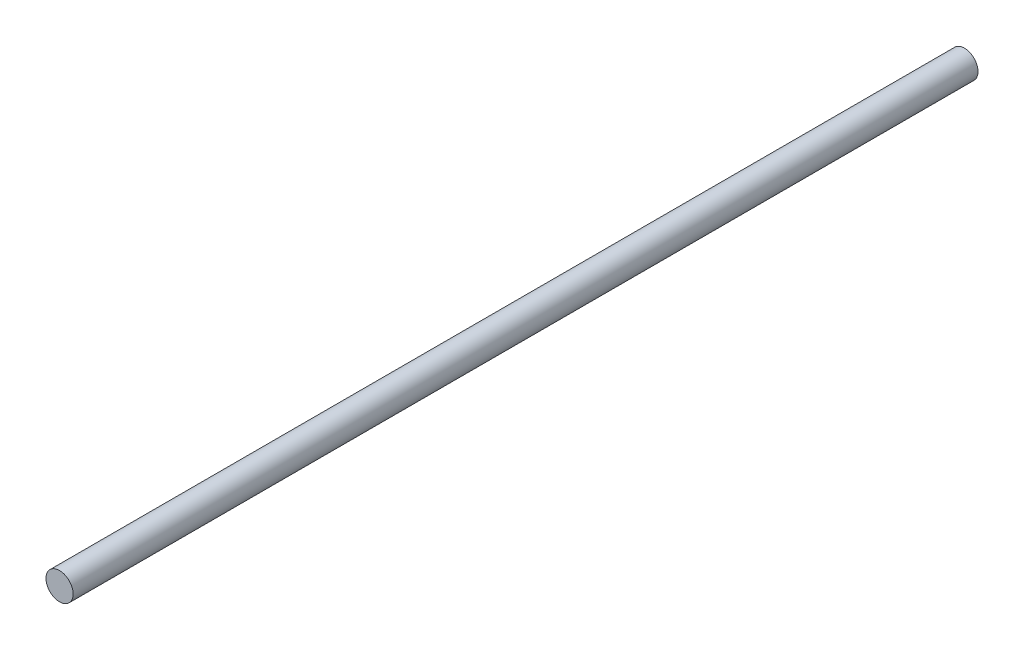
from build123d import *

# Parameters (mm, degrees)
SKETCH1_R           = 3
BOSS_EXTRUDE1_DEPTH = 100


with BuildPart() as part:
    # Sketch1 → Boss-Extrude1 (new body, symmetric)
    with BuildSketch(Plane.XY):
        Circle(SKETCH1_R)
    extrude(amount=BOSS_EXTRUDE1_DEPTH, both=True)


solid = part.part
